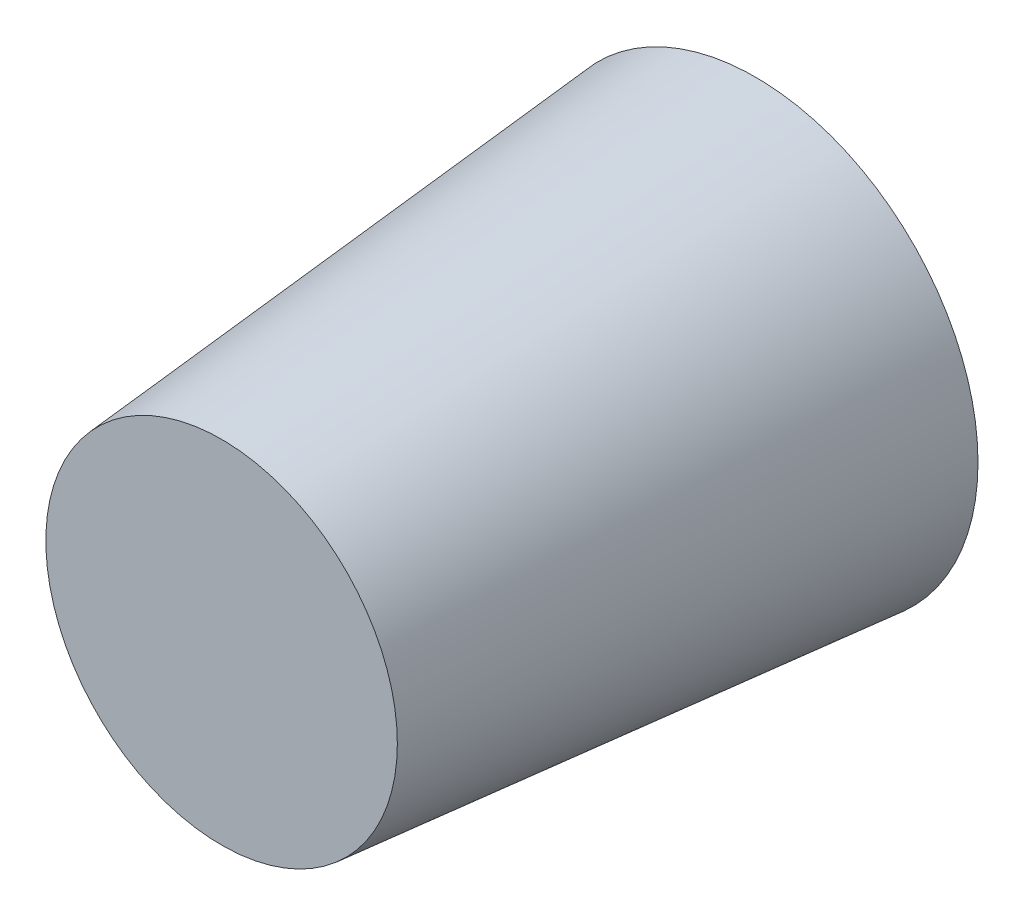
from build123d import *

# Parameters (mm, degrees)
CROQUIS2_R              = 2.5
SALIENTE_EXTRUIR1_DEPTH = 6
SALIENTE_EXTRUIR1_TAPER = 5
CROQUIS2_3_R            = 1.5
CORTAR_EXTRUIR1_DEPTH   = 5.5
CORTAR_EXTRUIR1_TAPER   = 5


with BuildPart() as part:
    # Croquis2 → Saliente-Extruir1 (new body)
    with BuildSketch(Plane.XY):
        with Locations((75, 144)):
            Circle(CROQUIS2_R)
    extrude(amount=SALIENTE_EXTRUIR1_DEPTH, taper=SALIENTE_EXTRUIR1_TAPER)

    # Croquis2_3 → Cortar-Extruir1 (cut)
    with BuildSketch(Plane.XY):
        with Locations((75, 144)):
            Circle(CROQUIS2_3_R)
    extrude(amount=CORTAR_EXTRUIR1_DEPTH, taper=CORTAR_EXTRUIR1_TAPER, mode=Mode.SUBTRACT)


solid = part.part
